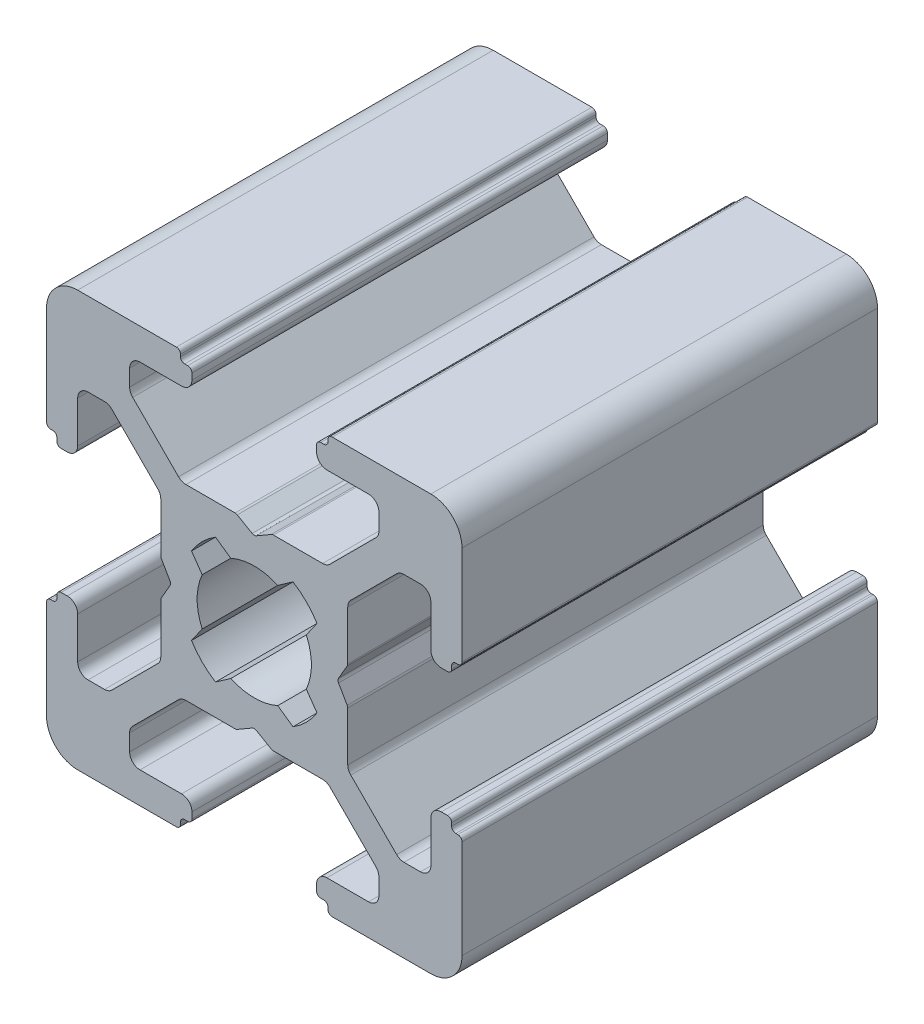
from build123d import *

# Parameters (mm, degrees)
EXTRUDE_1_DEPTH = 20


with BuildPart() as part:
    # Эскиз1 → Бобышка-Вытянуть1 (new body)
    with BuildSketch(Plane.XY):
        with BuildLine():
            Line((3, 9.3), (3, 9))
            ThreePointArc((3, 9), (3.146446609, 8.646446609), (3.5, 8.5))
            Line((3.5, 8.5), (5.5, 8.5))
            ThreePointArc((5.5, 8.5), (5.853553391, 8.353553391), (6, 8))
            Line((6, 8), (6, 7.208122677))
            ThreePointArc((6, 7.208122677), (5.961939766, 7.016780961), (5.853553391, 6.854569287))
            Line((5.853553391, 6.854569287), (3.645430713, 4.646446609))
            ThreePointArc((3.645430713, 4.646446609), (3.483219039, 4.538060234), (3.291877323, 4.5))
            Line((3.291877323, 4.5), (0.919615242, 4.5))
            ThreePointArc((0.919615242, 4.5), (0.867851433, 4.493185165), (0.819615242, 4.473205081))
            Line((0.819615242, 4.473205081), (0.1, 4.057735027))
            ThreePointArc((0.1, 4.057735027), (0, 4.030940108), (-0.1, 4.057735027))
            Line((-0.1, 4.057735027), (-0.819615242, 4.473205081))
            ThreePointArc((-0.819615242, 4.473205081), (-0.867851433, 4.493185165), (-0.919615242, 4.5))
            Line((-0.919615242, 4.5), (-3.291877323, 4.5))
            ThreePointArc((-3.291877323, 4.5), (-3.483219039, 4.538060234), (-3.645430713, 4.646446609))
            Line((-3.645430713, 4.646446609), (-5.853553391, 6.854569287))
            ThreePointArc((-5.853553391, 6.854569287), (-5.961939766, 7.016780961), (-6, 7.208122677))
            Line((-6, 7.208122677), (-6, 8))
            ThreePointArc((-6, 8), (-5.853553391, 8.353553391), (-5.5, 8.5))
            Line((-5.5, 8.5), (-3.5, 8.5))
            ThreePointArc((-3.5, 8.5), (-3.146446609, 8.646446609), (-3, 9))
            Line((-3, 9), (-3, 9.3))
            ThreePointArc((-3, 9.3), (-3.058578644, 9.441421356), (-3.2, 9.5))
            Line((-3.2, 9.5), (-3.35, 9.5))
            ThreePointArc((-3.35, 9.5), (-3.491421356, 9.558578644), (-3.55, 9.7))
            Line((-3.55, 9.7), (-3.55, 9.8))
            ThreePointArc((-3.55, 9.8), (-3.608578644, 9.941421356), (-3.75, 10))
            Line((-3.75, 10), (-8.5, 10))
            ThreePointArc((-8.5, 10), (-9.560660172, 9.560660172), (-10, 8.5))
            Line((-10, 8.5), (-10, 3.75))
            ThreePointArc((-10, 3.75), (-9.941421356, 3.608578644), (-9.8, 3.55))
            Line((-9.8, 3.55), (-9.7, 3.55))
            ThreePointArc((-9.7, 3.55), (-9.558578644, 3.491421356), (-9.5, 3.35))
            Line((-9.5, 3.35), (-9.5, 3.2))
            ThreePointArc((-9.5, 3.2), (-9.441421356, 3.058578644), (-9.3, 3))
            Line((-9.3, 3), (-9, 3))
            ThreePointArc((-9, 3), (-8.646446609, 3.146446609), (-8.5, 3.5))
            Line((-8.5, 3.5), (-8.5, 5.5))
            ThreePointArc((-8.5, 5.5), (-8.353553391, 5.853553391), (-8, 6))
            Line((-8, 6), (-7.208122677, 6))
            ThreePointArc((-7.208122677, 6), (-7.016780961, 5.961939766), (-6.854569287, 5.853553391))
            Line((-6.854569287, 5.853553391), (-4.646446609, 3.645430713))
            ThreePointArc((-4.646446609, 3.645430713), (-4.538060234, 3.483219039), (-4.5, 3.291877323))
            Line((-4.5, 3.291877323), (-4.5, 0.919615242))
            ThreePointArc((-4.5, 0.919615242), (-4.493185165, 0.867851433), (-4.473205081, 0.819615242))
            Line((-4.473205081, 0.819615242), (-4.057735027, 0.1))
            ThreePointArc((-4.057735027, 0.1), (-4.030940108, 0), (-4.057735027, -0.1))
            Line((-4.057735027, -0.1), (-4.473205081, -0.819615242))
            ThreePointArc((-4.473205081, -0.819615242), (-4.493185165, -0.867851433), (-4.5, -0.919615242))
            Line((-4.5, -0.919615242), (-4.5, -3.291877323))
            ThreePointArc((-4.5, -3.291877323), (-4.538060234, -3.483219039), (-4.646446609, -3.645430713))
            Line((-4.646446609, -3.645430713), (-6.854569287, -5.853553391))
            ThreePointArc((-6.854569287, -5.853553391), (-7.016780961, -5.961939766), (-7.208122677, -6))
            Line((-7.208122677, -6), (-8, -6))
            ThreePointArc((-8, -6), (-8.353553391, -5.853553391), (-8.5, -5.5))
            Line((-8.5, -5.5), (-8.5, -3.5))
            ThreePointArc((-8.5, -3.5), (-8.646446609, -3.146446609), (-9, -3))
            Line((-9, -3), (-9.3, -3))
            ThreePointArc((-9.3, -3), (-9.441421356, -3.058578644), (-9.5, -3.2))
            Line((-9.5, -3.2), (-9.5, -3.35))
            ThreePointArc((-9.5, -3.35), (-9.558578644, -3.491421356), (-9.7, -3.55))
            Line((-9.7, -3.55), (-9.8, -3.55))
            ThreePointArc((-9.8, -3.55), (-9.941421356, -3.608578644), (-10, -3.75))
            Line((-10, -3.75), (-10, -8.5))
            ThreePointArc((-10, -8.5), (-9.560660172, -9.560660172), (-8.5, -10))
            Line((-8.5, -10), (-3.75, -10))
            ThreePointArc((-3.75, -10), (-3.608578644, -9.941421356), (-3.55, -9.8))
            Line((-3.55, -9.8), (-3.55, -9.7))
            ThreePointArc((-3.55, -9.7), (-3.491421356, -9.558578644), (-3.35, -9.5))
            Line((-3.35, -9.5), (-3.2, -9.5))
            ThreePointArc((-3.2, -9.5), (-3.058578644, -9.441421356), (-3, -9.3))
            Line((-3, -9.3), (-3, -9))
            ThreePointArc((-3, -9), (-3.146446609, -8.646446609), (-3.5, -8.5))
            Line((-3.5, -8.5), (-5.5, -8.5))
            ThreePointArc((-5.5, -8.5), (-5.853553391, -8.353553391), (-6, -8))
            Line((-6, -8), (-6, -7.208122677))
            ThreePointArc((-6, -7.208122677), (-5.961939766, -7.016780961), (-5.853553391, -6.854569287))
            Line((-5.853553391, -6.854569287), (-3.645430713, -4.646446609))
            ThreePointArc((-3.645430713, -4.646446609), (-3.483219039, -4.538060234), (-3.291877323, -4.5))
            Line((-3.291877323, -4.5), (-0.919615242, -4.5))
            ThreePointArc((-0.919615242, -4.5), (-0.867851433, -4.493185165), (-0.819615242, -4.473205081))
            Line((-0.819615242, -4.473205081), (-0.1, -4.057735027))
            ThreePointArc((-0.1, -4.057735027), (0, -4.030940108), (0.1, -4.057735027))
            Line((0.1, -4.057735027), (0.819615242, -4.473205081))
            ThreePointArc((0.819615242, -4.473205081), (0.867851433, -4.493185165), (0.919615242, -4.5))
            Line((0.919615242, -4.5), (3.291877323, -4.5))
            ThreePointArc((3.291877323, -4.5), (3.483219039, -4.538060234), (3.645430713, -4.646446609))
            Line((3.645430713, -4.646446609), (5.853553391, -6.854569287))
            ThreePointArc((5.853553391, -6.854569287), (5.961939766, -7.016780961), (6, -7.208122677))
            Line((6, -7.208122677), (6, -8))
            ThreePointArc((6, -8), (5.853553391, -8.353553391), (5.5, -8.5))
            Line((5.5, -8.5), (3.5, -8.5))
            ThreePointArc((3.5, -8.5), (3.146446609, -8.646446609), (3, -9))
            Line((3, -9), (3, -9.3))
            ThreePointArc((3, -9.3), (3.058578644, -9.441421356), (3.2, -9.5))
            Line((3.2, -9.5), (3.35, -9.5))
            ThreePointArc((3.35, -9.5), (3.491421356, -9.558578644), (3.55, -9.7))
            Line((3.55, -9.7), (3.55, -9.8))
            ThreePointArc((3.55, -9.8), (3.608578644, -9.941421356), (3.75, -10))
            Line((3.75, -10), (8.5, -10))
            ThreePointArc((8.5, -10), (9.560660172, -9.560660172), (10, -8.5))
            Line((10, -8.5), (10, -3.75))
            ThreePointArc((10, -3.75), (9.941421356, -3.608578644), (9.8, -3.55))
            Line((9.8, -3.55), (9.7, -3.55))
            ThreePointArc((9.7, -3.55), (9.558578644, -3.491421356), (9.5, -3.35))
            Line((9.5, -3.35), (9.5, -3.2))
            ThreePointArc((9.5, -3.2), (9.441421356, -3.058578644), (9.3, -3))
            Line((9.3, -3), (9, -3))
            ThreePointArc((9, -3), (8.646446609, -3.146446609), (8.5, -3.5))
            Line((8.5, -3.5), (8.5, -5.5))
            ThreePointArc((8.5, -5.5), (8.353553391, -5.853553391), (8, -6))
            Line((8, -6), (7.208122677, -6))
            ThreePointArc((7.208122677, -6), (7.016780961, -5.961939766), (6.854569287, -5.853553391))
            Line((6.854569287, -5.853553391), (4.646446609, -3.645430713))
            ThreePointArc((4.646446609, -3.645430713), (4.538060234, -3.483219039), (4.5, -3.291877323))
            Line((4.5, -3.291877323), (4.5, -0.919615242))
            ThreePointArc((4.5, -0.919615242), (4.493185165, -0.867851433), (4.473205081, -0.819615242))
            Line((4.473205081, -0.819615242), (4.057735027, -0.1))
            ThreePointArc((4.057735027, -0.1), (4.030940108, 0), (4.057735027, 0.1))
            Line((4.057735027, 0.1), (4.473205081, 0.819615242))
            ThreePointArc((4.473205081, 0.819615242), (4.493185165, 0.867851433), (4.5, 0.919615242))
            Line((4.5, 0.919615242), (4.5, 3.291877323))
            ThreePointArc((4.5, 3.291877323), (4.538060234, 3.483219039), (4.646446609, 3.645430713))
            Line((4.646446609, 3.645430713), (6.854569287, 5.853553391))
            ThreePointArc((6.854569287, 5.853553391), (7.016780961, 5.961939766), (7.208122677, 6))
            Line((7.208122677, 6), (8, 6))
            ThreePointArc((8, 6), (8.353553391, 5.853553391), (8.5, 5.5))
            Line((8.5, 5.5), (8.5, 3.5))
            ThreePointArc((8.5, 3.5), (8.646446609, 3.146446609), (9, 3))
            Line((9, 3), (9.3, 3))
            ThreePointArc((9.3, 3), (9.441421356, 3.058578644), (9.5, 3.2))
            Line((9.5, 3.2), (9.5, 3.35))
            ThreePointArc((9.5, 3.35), (9.558578644, 3.491421356), (9.7, 3.55))
            Line((9.7, 3.55), (9.8, 3.55))
            ThreePointArc((9.8, 3.55), (9.941421356, 3.608578644), (10, 3.75))
            Line((10, 3.75), (10, 8.5))
            ThreePointArc((10, 8.5), (9.560660172, 9.560660172), (8.5, 10))
            Line((8.5, 10), (3.75, 10))
            ThreePointArc((3.75, 10), (3.608578644, 9.941421356), (3.55, 9.8))
            Line((3.55, 9.8), (3.55, 9.7))
            ThreePointArc((3.55, 9.7), (3.491421356, 9.558578644), (3.35, 9.5))
            Line((3.35, 9.5), (3.2, 9.5))
            ThreePointArc((3.2, 9.5), (3.058578644, 9.441421356), (3, 9.3))
        make_face()
        with BuildLine():
            Line((-3.020442772, 1.865321812), (-2.506504586, 1.131342017))
            ThreePointArc((-2.506504586, 1.131342017), (-2.75, 0), (-2.506504586, -1.131342017))
            Line((-2.506504586, -1.131342017), (-3.020442772, -1.865321812))
            ThreePointArc((-3.020442772, -1.865321812), (-2.510229073, -2.510229073), (-1.865321812, -3.020442772))
            Line((-1.865321812, -3.020442772), (-1.131342017, -2.506504586))
            ThreePointArc((-1.131342017, -2.506504586), (0, -2.75), (1.131342017, -2.506504586))
            Line((1.131342017, -2.506504586), (1.865321812, -3.020442772))
            ThreePointArc((1.865321812, -3.020442772), (2.510229073, -2.510229073), (3.020442772, -1.865321812))
            Line((3.020442772, -1.865321812), (2.506504586, -1.131342017))
            ThreePointArc((2.506504586, -1.131342017), (2.75, 0), (2.506504586, 1.131342017))
            Line((2.506504586, 1.131342017), (3.020442772, 1.865321812))
            ThreePointArc((3.020442772, 1.865321812), (2.510229073, 2.510229073), (1.865321812, 3.020442772))
            Line((1.865321812, 3.020442772), (1.131342017, 2.506504586))
            ThreePointArc((1.131342017, 2.506504586), (0, 2.75), (-1.131342017, 2.506504586))
            Line((-1.131342017, 2.506504586), (-1.865321812, 3.020442772))
            ThreePointArc((-1.865321812, 3.020442772), (-2.510229073, 2.510229073), (-3.020442772, 1.865321812))
        make_face(mode=Mode.SUBTRACT)
    extrude(amount=EXTRUDE_1_DEPTH)


solid = part.part
